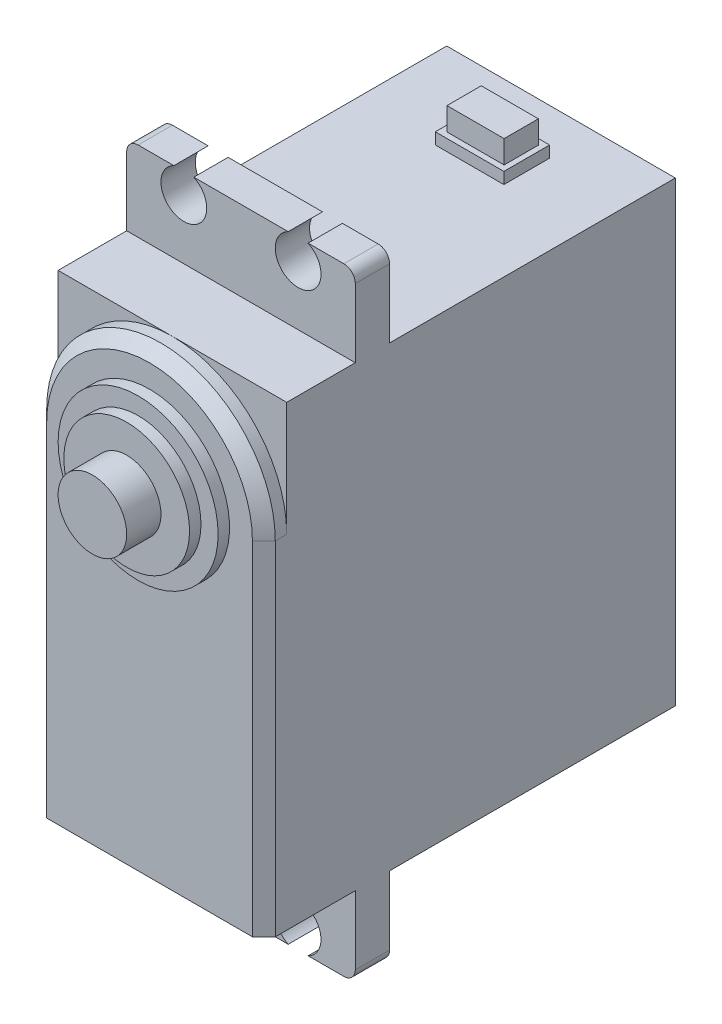
from build123d import *

# Parameters (mm, degrees)
SKETCH1_W            = 20
SKETCH1_H            = 40
BOSS_EXTRUDE1_DEPTH  = 36
CHAMFER1_SIZE        = 2
BOSS_EXTRUDE7_DEPTH  = 3
FILLET1_R            = 1
FILLET2_R            = 1
SKETCH3_W            = 6
SKETCH3_H            = 4
BOSS_EXTRUDE8_DEPTH  = 1
SKETCH4_W            = 5
SKETCH4_H            = 3
BOSS_EXTRUDE9_DEPTH  = 2
BOSS_EXTRUDE10_DEPTH = 2
CHAMFER2_SIZE        = 1
SKETCH6_R            = 7
BOSS_EXTRUDE11_DEPTH = 1
SKETCH7_R            = 5.5
BOSS_EXTRUDE12_DEPTH = 1
SKETCH8_R            = 3
BOSS_EXTRUDE13_DEPTH = 3


with BuildPart() as part:
    # Sketch1 → Boss-Extrude1 (new body)
    with BuildSketch(Plane.XY):
        Rectangle(SKETCH1_W, SKETCH1_H)
    extrude(amount=BOSS_EXTRUDE1_DEPTH)

    # Chamfer1
    chamfer1_edges = [part.edges().sort_by_distance(p)[0] for p in [
        (0, -20, 0),
        (-10, 0, 0),
        (0, 20, 0),
        (10, 0, 0),
    ]]
    chamfer(chamfer1_edges, length=CHAMFER1_SIZE)

    # Sketch2 → Boss-Extrude7 (add)
    with BuildSketch(Plane.XY.offset(27)):
        with BuildLine():
            Line((-10, 20), (10, 20))
            Line((10, 20), (10, 27))
            Line((10, 27), (5.871779789, 27))
            ThreePointArc((5.871779789, 27), (5, 23.2), (4.128220211, 27))
            Line((4.128220211, 27), (-4.128220211, 27))
            ThreePointArc((-4.128220211, 27), (-5, 23.2), (-5.871779789, 27))
            Line((-5.871779789, 27), (-10, 27))
            Line((-10, 27), (-10, 20))
        make_face()
    boss_extrude7 = extrude(amount=BOSS_EXTRUDE7_DEPTH)

    # Fillet1
    fillet1_edges = [part.edges().sort_by_distance(p)[0] for p in [
        (10, 27, 28.5),
        (-10, 27, 28.5),
    ]]
    fillet(fillet1_edges, radius=FILLET1_R)

    # Mirror1: Boss-Extrude7 across plane
    add(boss_extrude7.mirror(Plane.ZX))

    # Fillet2
    fillet2_edges = [part.edges().sort_by_distance(p)[0] for p in [
        (-10, -27, 28.5),
        (10, -27, 28.5),
    ]]
    fillet(fillet2_edges, radius=FILLET2_R)

    # Sketch3 → Boss-Extrude8 (add)
    with BuildSketch(Plane(origin=(0, 20, 0), x_dir=(1, 0, 0), z_dir=(0, 1, 0))):
        with Locations((0, -8)):
            Rectangle(SKETCH3_W, SKETCH3_H)
    extrude(amount=BOSS_EXTRUDE8_DEPTH)

    # Sketch4 → Boss-Extrude9 (add)
    with BuildSketch(Plane(origin=(0, 21, 0), x_dir=(1, 0, 0), z_dir=(0, 1, 0))):
        with Locations((0.024838868, -8.004270903)):
            Rectangle(SKETCH4_W, SKETCH4_H)
    extrude(amount=BOSS_EXTRUDE9_DEPTH)

    # Sketch5 → Boss-Extrude10 (add)
    with BuildSketch(Plane.XY.offset(36)):
        with BuildLine():
            Line((-10, 10), (-10, -20))
            Line((-10, -20), (10, -20))
            Line((10, -20), (10, 10))
            ThreePointArc((10, 10), (0, 20), (-10, 10))
        make_face()
    extrude(amount=BOSS_EXTRUDE10_DEPTH)

    # Chamfer2
    chamfer2_edges = [part.edges().sort_by_distance(p)[0] for p in [
        (10, -5, 38),
        (0, 20, 38),
        (-10, -5, 38),
    ]]
    chamfer(chamfer2_edges, length=CHAMFER2_SIZE)

    # Sketch6 → Boss-Extrude11 (add)
    with BuildSketch(Plane.XY.offset(38)):
        with Locations((0, 10)):
            Circle(SKETCH6_R)
    extrude(amount=BOSS_EXTRUDE11_DEPTH)

    # Sketch7 → Boss-Extrude12 (add)
    with BuildSketch(Plane.XY.offset(39)):
        with Locations((0, 10)):
            Circle(SKETCH7_R)
    extrude(amount=BOSS_EXTRUDE12_DEPTH)

    # Sketch8 → Boss-Extrude13 (add)
    with BuildSketch(Plane.XY.offset(40)):
        with Locations((0, 10)):
            Circle(SKETCH8_R)
    extrude(amount=BOSS_EXTRUDE13_DEPTH)


solid = part.part
